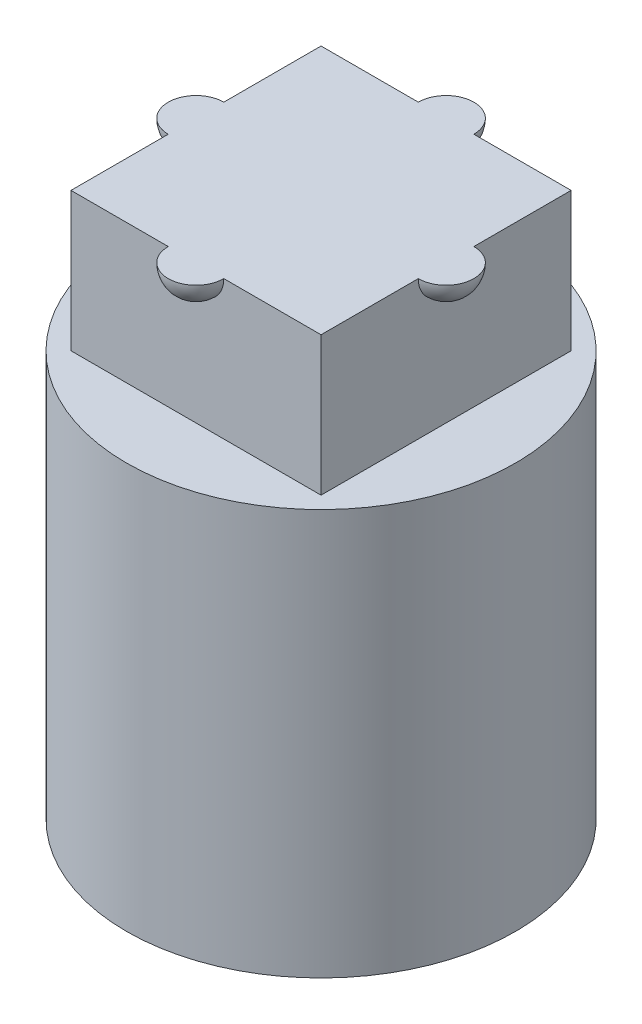
from build123d import *

# Parameters (mm, degrees)
SKETCH_1_R          = 3.5
EXTRUDE_1_DEPTH     = 4
SKETCH_3_R          = 3.5
EXTRUDE_2_DEPTH     = 3.3
SKETCH_4_W          = 4.5
SKETCH_4_H          = 4.5
EXTRUDE_3_DEPTH     = 2.5
SKETCH_7_R          = 3.5
CUT_EXTRUDE_1_DEPTH = 10


with BuildPart() as part:
    # 草图1 → 凸台-拉伸1 (new body)
    with BuildSketch(Plane(origin=(0, 0, 0), x_dir=(1, 0, 0), z_dir=(0, 1, 0))):
        Circle(SKETCH_1_R)
        with BuildLine():
            Line((0.95, -1.2), (-0.95, -1.2))
            ThreePointArc((-0.95, -1.2), (-1.376776695, -1.376776695), (-1.2, -0.95))
            Line((-1.2, -0.95), (-1.2, 0.95))
            ThreePointArc((-1.2, 0.95), (-1.376776695, 1.376776695), (-0.95, 1.2))
            Line((-0.95, 1.2), (0.95, 1.2))
            ThreePointArc((0.95, 1.2), (1.376776695, 1.376776695), (1.2, 0.95))
            Line((1.2, 0.95), (1.2, -0.95))
            ThreePointArc((1.2, -0.95), (1.376776695, -1.376776695), (0.95, -1.2))
        make_face(mode=Mode.SUBTRACT)
    extrude(amount=EXTRUDE_1_DEPTH)

    # 草图3 → 凸台-拉伸2 (add)
    with BuildSketch(Plane(origin=(0, 4, 0), x_dir=(1, 0, 0), z_dir=(0, 1, 0))):
        Circle(SKETCH_3_R)
    extrude(amount=EXTRUDE_2_DEPTH)

    # 草图4 → 凸台-拉伸3 (add)
    with BuildSketch(Plane(origin=(0, 7.3, 0), x_dir=(1, 0, 0), z_dir=(0, 1, 0))):
        Rectangle(SKETCH_4_W, SKETCH_4_H)
    extrude(amount=EXTRUDE_3_DEPTH)

    # 草图5 → 旋转1 (revolve)
    with BuildSketch(Plane(origin=(0, 9.8, 0), x_dir=(1, 0, 0), z_dir=(0, 1, 0))):
        with BuildLine():
            Line((-2.75, 0), (-1.75, 0))
            ThreePointArc((-1.75, 0), (-2.25, -0.5), (-2.75, 0))
        make_face()
        with BuildLine():
            Line((1.75, 0), (2.75, 0))
            ThreePointArc((2.75, 0), (2.25, -0.5), (1.75, 0))
        make_face()
    revolve(axis=Axis((-2.75, 9.8, 0), (1, 0, 0)))

    # 草图6 → 旋转2 (revolve)
    with BuildSketch(Plane(origin=(0, 9.8, 0), x_dir=(1, 0, 0), z_dir=(0, 1, 0))):
        with BuildLine():
            Line((0, -2.75), (0, -1.75))
            ThreePointArc((0, -1.75), (-0.5, -2.25), (0, -2.75))
        make_face()
        with BuildLine():
            Line((0, 1.75), (0, 2.75))
            ThreePointArc((0, 2.75), (-0.5, 2.25), (0, 1.75))
        make_face()
    revolve(axis=Axis((0, 9.8, 2.75), (0, 0, -1)))

    # 草图7 → 切除-拉伸1 (cut)
    with BuildSketch(Plane(origin=(0, 9.8, 0), x_dir=(1, 0, 0), z_dir=(0, 1, 0))):
        Circle(SKETCH_7_R)
    extrude(amount=CUT_EXTRUDE_1_DEPTH, mode=Mode.SUBTRACT)


solid = part.part
